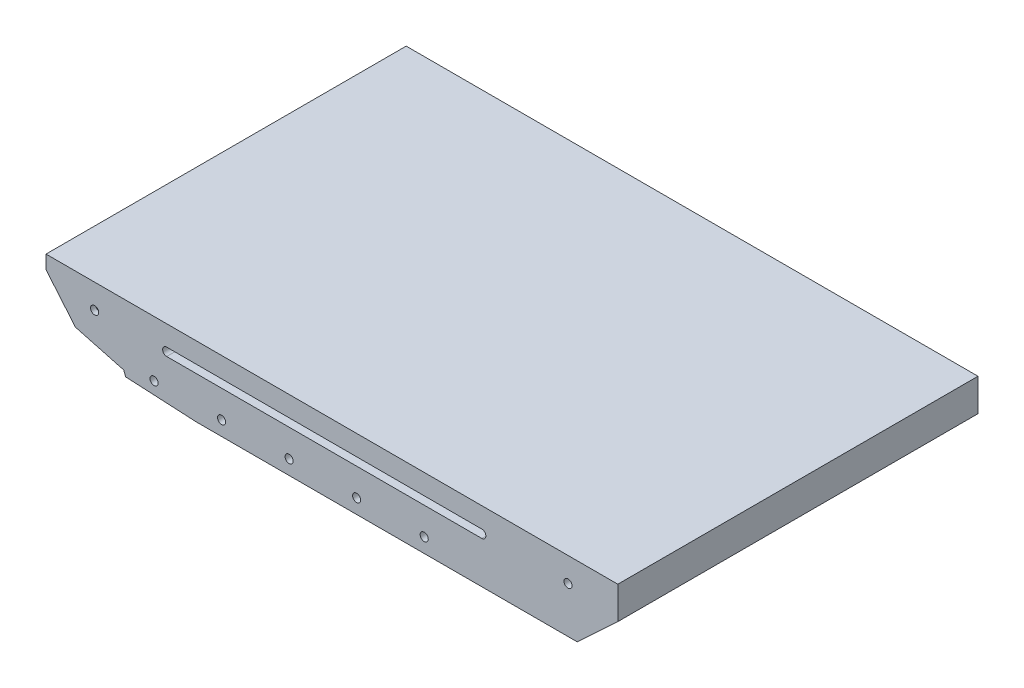
from build123d import *

# Parameters (mm, degrees)
BOSS_EXTRUDE1_DEPTH     = 200
CUT_EXTRUDE1_DEPTH      = 1875
CUT_EXTRUDE2_DEPTH      = 1
CUT_EXTRUDE2_DEPTH_BACK = 401
SKETCH9_R               = 4.5
CUT_EXTRUDE8_DEPTH      = 535
SKETCH10_W              = 407.608738225
SKETCH10_H              = 383.631753623
CUT_EXTRUDE9_DEPTH      = 40
SKETCH11_W              = 54.119479529
SKETCH11_H              = 34.252835145
SKETCH11_W_2            = 48.255495223
SKETCH11_H_2            = 39.048232065
CUT_EXTRUDE10_DEPTH     = 25


with BuildPart() as part:
    # Sketch1 → Boss-Extrude1 (new body, symmetric)
    with BuildSketch(Plane.XY):
        Polygon((295, 0), (340, 41.963178876), (340, 78), (-295, 78), (-295, 0), align=None)
    extrude(amount=BOSS_EXTRUDE1_DEPTH, both=True)

    # Sketch2 → Cut-Extrude1 (cut)
    with BuildSketch(Plane.XY.offset(200)):
        Polygon((-247.386799314, 6.256797028), (-295, 63), (-295, 0), (-128, 0), align=None)
    extrude(amount=-CUT_EXTRUDE1_DEPTH, mode=Mode.SUBTRACT)

    # Sketch3 → Cut-Extrude2 (cut, two sides)
    with BuildSketch(Plane.XY.offset(200)) as cut_extrude2_sk:
        Polygon((250.288603953, -1126.47745776), (-206.5, 4.114010674), (-208.74763956, 9.677113801), (-262.275114384, 24), (-1440.216479918, 339.193649301), (-3037.790452197, -1503.448201922), (-1347.285368327, -2969.119308982), align=None)
    extrude(amount=CUT_EXTRUDE2_DEPTH, mode=Mode.SUBTRACT)
    extrude(cut_extrude2_sk.sketch, amount=-CUT_EXTRUDE2_DEPTH_BACK, mode=Mode.SUBTRACT)

    # Sketch9 → Cut-Extrude8 (cut, symmetric)
    with BuildSketch(Plane.XY):
        with Locations((-175, 16)):
            Circle(SKETCH9_R)
        with Locations((-100, 16)):
            Circle(SKETCH9_R)
        with Locations((-25, 16)):
            Circle(SKETCH9_R)
        with Locations((50, 16)):
            Circle(SKETCH9_R)
        with Locations((125, 16)):
            Circle(SKETCH9_R)
        with Locations((-241, 51)):
            Circle(SKETCH9_R)
        with Locations((284.7, 51)):
            Circle(SKETCH9_R)
        with BuildLine():
            Line((-161, 55.5), (189, 55.5))
            ThreePointArc((189, 55.5), (193.5, 51), (189, 46.5))
            Line((189, 46.5), (-161, 46.5))
            ThreePointArc((-161, 46.5), (-165.5, 51), (-161, 55.5))
        make_face()
    extrude(amount=CUT_EXTRUDE8_DEPTH, both=True, mode=Mode.SUBTRACT)

    # Sketch10 → Cut-Extrude9 (cut)
    with BuildSketch(Plane(origin=(0, 0, 0), x_dir=(1, 0, 0), z_dir=(0, 1, 0))):
        with Locations((84.497631613, 1.027585054)):
            Rectangle(SKETCH10_W, SKETCH10_H)
    extrude(amount=CUT_EXTRUDE9_DEPTH, mode=Mode.SUBTRACT)

    # Sketch11 → Cut-Extrude10 (cut, symmetric)
    with BuildSketch(Plane.XZ.offset(-40)):
        with Locations((295.495096106, -172.29176078)):
            Rectangle(SKETCH11_W, SKETCH11_H)
        with Locations((-232.875387171, -174.68945924)):
            Rectangle(SKETCH11_W_2, SKETCH11_H_2)
        with Locations((295.495096106, 172.29176078)):
            Rectangle(SKETCH11_W, SKETCH11_H)
        with Locations((-232.875387171, 174.68945924)):
            Rectangle(SKETCH11_W_2, SKETCH11_H_2)
    extrude(amount=CUT_EXTRUDE10_DEPTH, both=True, mode=Mode.SUBTRACT)


solid = part.part
